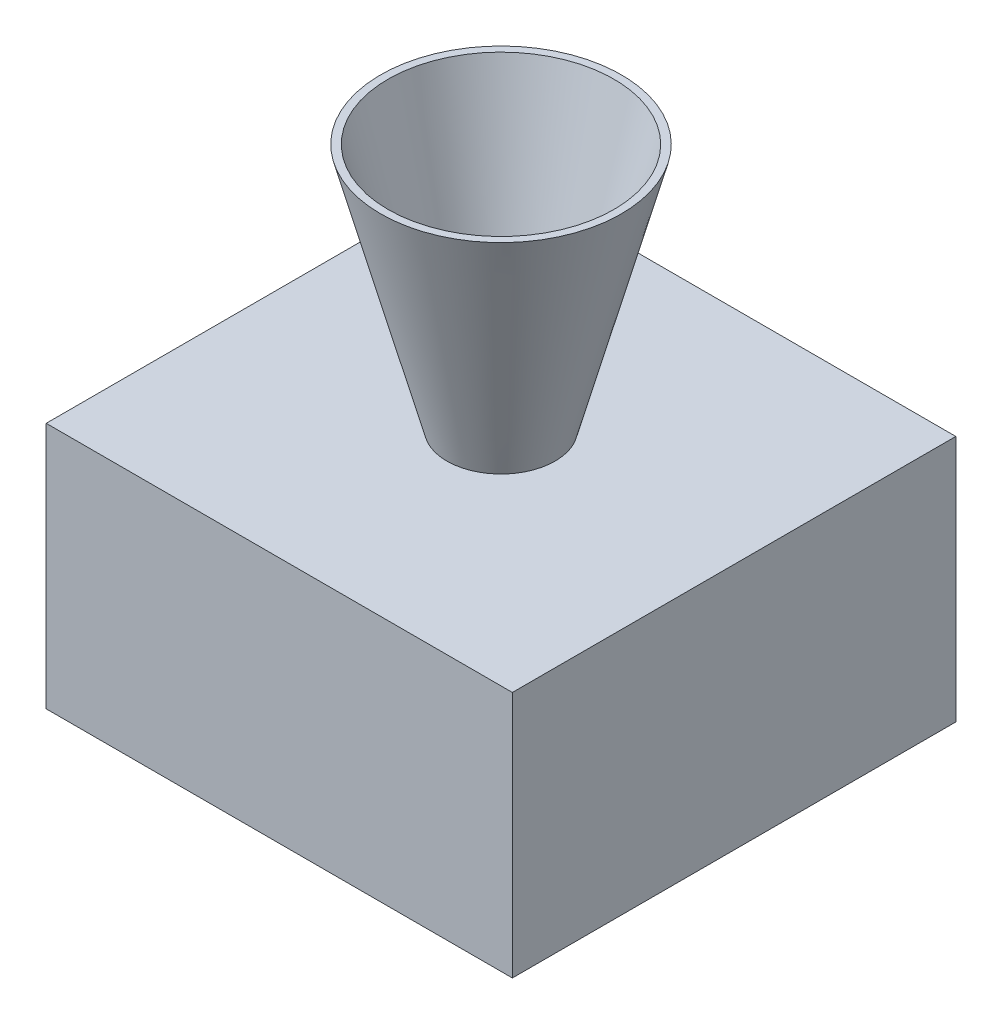
from build123d import *

# Parameters (mm, degrees)
SKETCH1_W           = 164
SKETCH1_H           = 156
BOSS_EXTRUDE2_DEPTH = 87
SKETCH2_R           = 19.05
BOSS_EXTRUDE3_DEPTH = 87
BOSS_EXTRUDE3_DRAFT = -15
SHELL1_T            = -2.54


with BuildPart() as part:
    # Sketch1 → Boss-Extrude2 (new body)
    with BuildSketch(Plane(origin=(0, 0, 0), x_dir=(1, 0, 0), z_dir=(0, 1, 0))):
        Rectangle(SKETCH1_W, SKETCH1_H)
    extrude(amount=BOSS_EXTRUDE2_DEPTH)


with BuildPart() as boss_extrude3_tool:
    # Sketch2 → Boss-Extrude3 (with draft: the straight prism first)
    with BuildSketch(Plane(origin=(0, 87, 0), x_dir=(1, 0, 0), z_dir=(0, 1, 0))):
        Circle(SKETCH2_R)
    extrude(amount=BOSS_EXTRUDE3_DEPTH)
    # Boss-Extrude3: the draft: its side faces are tilted about the plane it starts from
    boss_extrude3_sides = [boss_extrude3_tool.faces().sort_by_distance(p)[0] for p in [
        (-19.05, 130.5, 0),
    ]]
    draft(boss_extrude3_sides, Plane(origin=(0, 87, 0), x_dir=(1, 0, 0), z_dir=(0, 1, 0)), BOSS_EXTRUDE3_DRAFT)


with BuildPart() as part_1:
    add(part.part)

    # Boss-Extrude3: add boss_extrude3_tool
    add(boss_extrude3_tool.part)

    # Shell1
    shell1_openings = [part_1.faces().sort_by_distance(p)[0] for p in [
        (0, 174, 0),
    ]]
    offset(amount=SHELL1_T, openings=shell1_openings, kind=Kind.INTERSECTION)


solid = part_1.part
